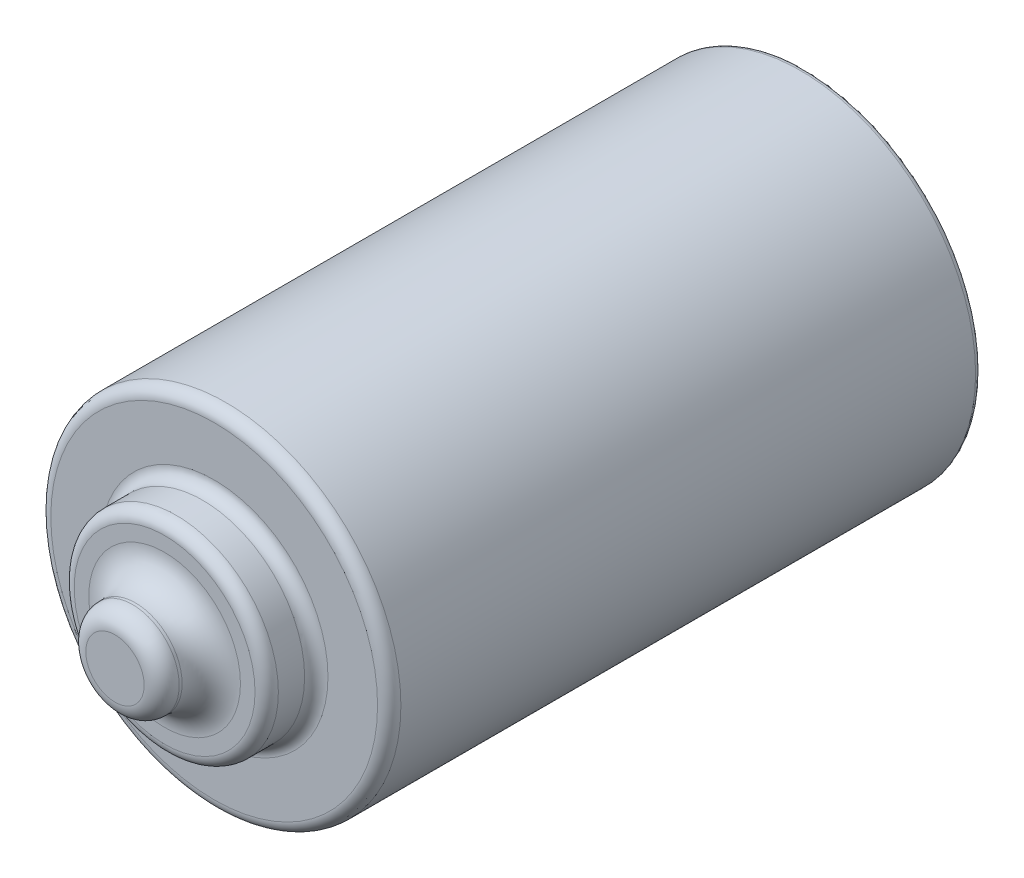
from build123d import *

# Parameters (mm, degrees)
CROQUIS1_R              = 30
SALIENTE_EXTRUIR1_DEPTH = 101.5
CROQUIS2_R              = 17.5
SALIENTE_EXTRUIR2_DEPTH = 8.5
CROQUIS3_R              = 8
SALIENTE_EXTRUIR3_DEPTH = 8.5
CROQUIS4_R              = 16
SALIENTE_EXTRUIR4_DEPTH = 2.5
REDONDEO1_R             = 2
REDONDEO2_R             = 2
REDONDEO3_R             = 2
REDONDEO4_R             = 5
REDONDEO5_R             = 3
REDONDEO6_R             = 1
REDONDEO7_R             = 1


with BuildPart() as part:
    # Croquis1 → Saliente-Extruir1 (new body)
    with BuildSketch(Plane.XY):
        Circle(CROQUIS1_R)
    extrude(amount=SALIENTE_EXTRUIR1_DEPTH)

    # Croquis2 → Saliente-Extruir2 (add)
    with BuildSketch(Plane.XY.offset(101.5)):
        Circle(CROQUIS2_R)
    extrude(amount=SALIENTE_EXTRUIR2_DEPTH)

    # Croquis3 → Saliente-Extruir3 (add)
    with BuildSketch(Plane.XY.offset(110)):
        Circle(CROQUIS3_R)
    extrude(amount=SALIENTE_EXTRUIR3_DEPTH)

    # Croquis4 → Saliente-Extruir4 (add)
    with BuildSketch(Plane(origin=(0, 0, 0), x_dir=(-1, 0, 0), z_dir=(0, 0, -1))):
        Circle(CROQUIS4_R)
    extrude(amount=SALIENTE_EXTRUIR4_DEPTH)

    # Redondeo1
    redondeo1_edges = [part.edges().sort_by_distance(p)[0] for p in [
        (-30, 0, 101.5),
    ]]
    fillet(redondeo1_edges, radius=REDONDEO1_R)

    # Redondeo2
    redondeo2_edges = [part.edges().sort_by_distance(p)[0] for p in [
        (-17.5, 0, 101.5),
    ]]
    fillet(redondeo2_edges, radius=REDONDEO2_R)

    # Redondeo3
    redondeo3_edges = [part.edges().sort_by_distance(p)[0] for p in [
        (-17.5, 0, 110),
    ]]
    fillet(redondeo3_edges, radius=REDONDEO3_R)

    # Redondeo4
    redondeo4_edges = [part.edges().sort_by_distance(p)[0] for p in [
        (-8, 0, 110),
    ]]
    fillet(redondeo4_edges, radius=REDONDEO4_R)

    # Redondeo5
    redondeo5_edges = [part.edges().sort_by_distance(p)[0] for p in [
        (-8, 0, 118.5),
    ]]
    fillet(redondeo5_edges, radius=REDONDEO5_R)

    # Redondeo6
    redondeo6_edges = [part.edges().sort_by_distance(p)[0] for p in [
        (-30, 0, 0),
    ]]
    fillet(redondeo6_edges, radius=REDONDEO6_R)

    # Redondeo7
    redondeo7_edges = [part.edges().sort_by_distance(p)[0] for p in [
        (16, 0, -2.5),
    ]]
    fillet(redondeo7_edges, radius=REDONDEO7_R)


solid = part.part
